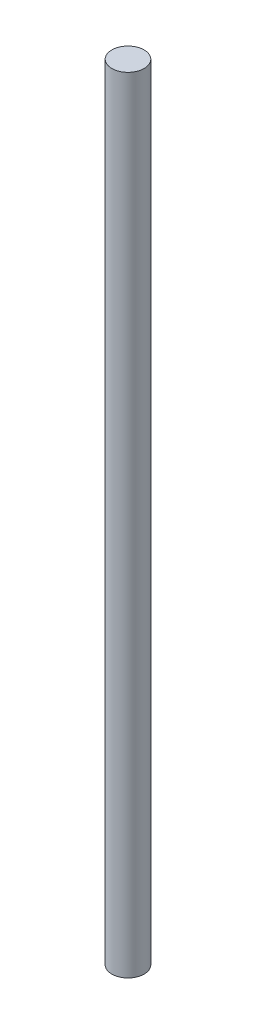
from build123d import *

# Parameters (mm, degrees)
SKETCH1_R           = 2.675
BOSS_EXTRUDE1_DEPTH = 130


with BuildPart() as part:
    # Sketch1 → Boss-Extrude1 (new body)
    with BuildSketch(Plane(origin=(0, 0, 0), x_dir=(1, 0, 0), z_dir=(0, 1, 0))):
        Circle(SKETCH1_R)
    extrude(amount=BOSS_EXTRUDE1_DEPTH)


solid = part.part
